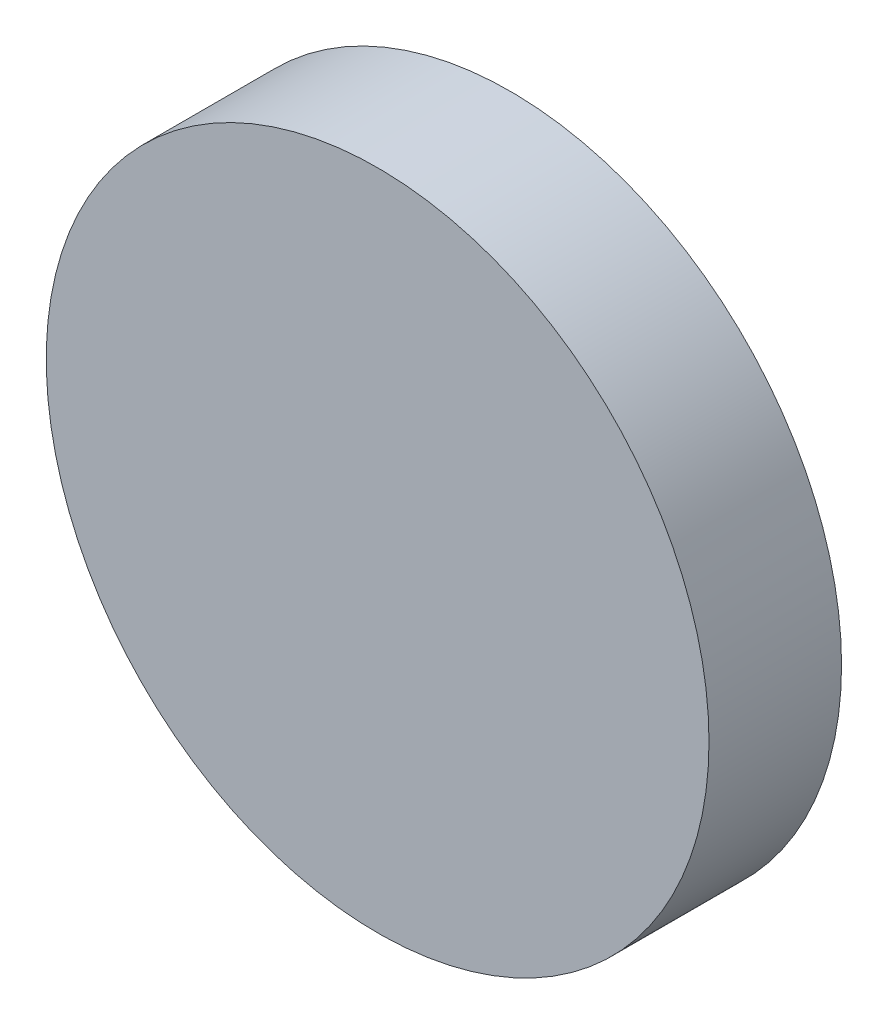
from build123d import *

# Parameters (mm, degrees)
SKETCH1_R           = 250
BOSS_EXTRUDE1_DEPTH = 100


with BuildPart() as part:
    # Sketch1 → Boss-Extrude1 (new body)
    with BuildSketch(Plane.XY):
        Circle(SKETCH1_R)
    extrude(amount=BOSS_EXTRUDE1_DEPTH)


solid = part.part
